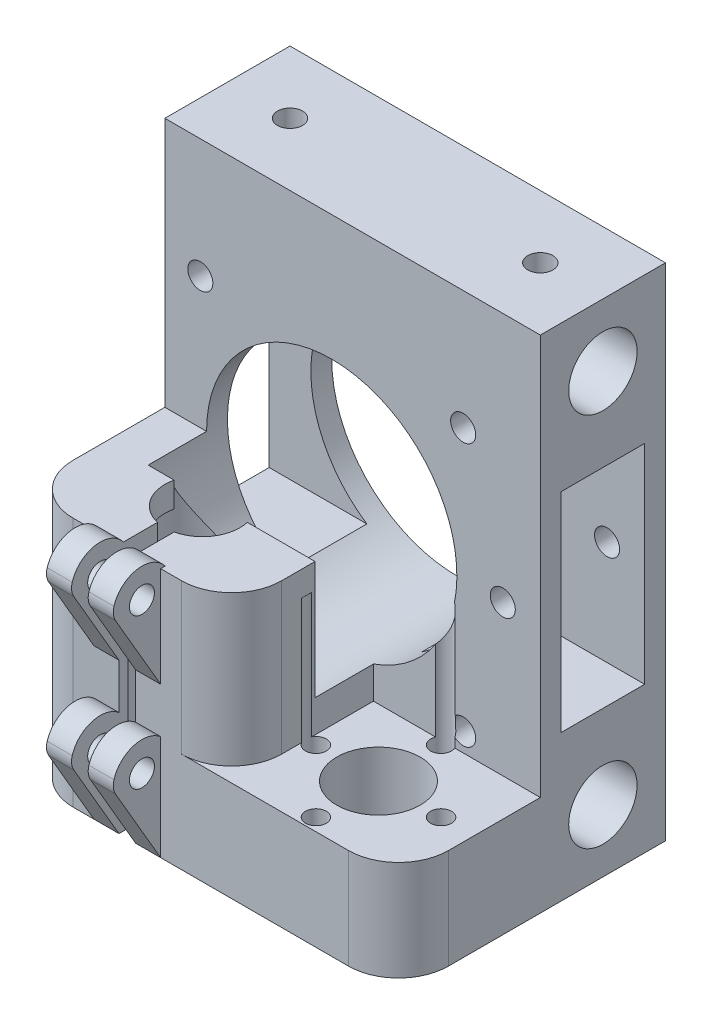
from build123d import *

# Parameters (mm, degrees)
SKETCH1_W           = 45
SKETCH1_H           = 60
BOSS_EXTRUDE1_DEPTH = 15
SKETCH2_R           = 4.1
SKETCH2_W           = 10
SKETCH2_H           = 25
CUT_EXTRUDE1_DEPTH  = 46
SKETCH3_W           = 17
SKETCH3_H           = 12
BOSS_EXTRUDE2_DEPTH = 45
SKETCH4_W           = 25
SKETCH4_H           = 17
BOSS_EXTRUDE3_DEPTH = 18
SKETCH5_W           = 2
SKETCH5_H           = 30
CUT_EXTRUDE2_DEPTH  = 5
SKETCH6_R           = 4.5
CUT_EXTRUDE3_DEPTH  = 61
SKETCH7_R           = 8
SKETCH7_R_2         = 5
SKETCH7_R_3         = 1.25
CUT_EXTRUDE4_DEPTH  = 27
SKETCH8_R           = 15
SKETCH8_R_2         = 1.5
CUT_EXTRUDE5_DEPTH  = 22
FILLET1_R           = 6
SKETCH9_R           = 1.5
CUT_EXTRUDE6_DEPTH  = 15
CUT_EXTRUDE7_REACH  = 62
SKETCH10_R          = 1.5
CUT_EXTRUDE8_START  = -60
SKETCH10_2_R        = 1.5
CUT_EXTRUDE8_DEPTH  = 3.684243
SKETCH11_R          = 1.5
BOSS_EXTRUDE4_DEPTH = 3
BOSS_EXTRUDE6_START = 2
SKETCH11_2_R        = 1.5
BOSS_EXTRUDE6_DEPTH = 3
FILLET3_R           = 2


with BuildPart() as part:
    # Sketch1 → Boss-Extrude1 (new body)
    with BuildSketch(Plane.XY):
        Rectangle(SKETCH1_W, SKETCH1_H)
    extrude(amount=BOSS_EXTRUDE1_DEPTH)

    # Sketch2 → Cut-Extrude1 (cut, through all)
    with BuildSketch(Plane(origin=(22.5, 0, 0), x_dir=(0, 0, -1), z_dir=(1, 0, 0))):
        with Locations((-7.5, 22.5)):
            Circle(SKETCH2_R)
        with Locations((-7.5, -22.5)):
            Circle(SKETCH2_R)
        with Locations((-7.5, 0)):
            Rectangle(SKETCH2_W, SKETCH2_H)
    extrude(amount=-CUT_EXTRUDE1_DEPTH, mode=Mode.SUBTRACT)

    # Sketch3 → Boss-Extrude2 (add)
    with BuildSketch(Plane.ZY.offset(22.5)):
        with Locations((23.5, -24)):
            Rectangle(SKETCH3_W, SKETCH3_H)
    extrude(amount=-BOSS_EXTRUDE2_DEPTH)

    # Sketch4 → Boss-Extrude3 (add)
    with BuildSketch(Plane(origin=(0, -18, 0), x_dir=(1, 0, 0), z_dir=(0, 1, 0))):
        with Locations((-10, -23.5)):
            Rectangle(SKETCH4_W, SKETCH4_H)
    extrude(amount=BOSS_EXTRUDE3_DEPTH)

    # Sketch5 → Cut-Extrude2 (cut)
    with BuildSketch(Plane.XY.offset(32)):
        with Locations((-10, -15)):
            Rectangle(SKETCH5_W, SKETCH5_H)
    extrude(amount=-CUT_EXTRUDE2_DEPTH, mode=Mode.SUBTRACT)

    # Sketch6 → Cut-Extrude3 (cut, through all)
    with BuildSketch(Plane.XZ.offset(30)):
        with Locations((-10, 23)):
            Circle(SKETCH6_R)
    extrude(amount=-CUT_EXTRUDE3_DEPTH, mode=Mode.SUBTRACT)

    # Sketch7 → Cut-Extrude4 (cut)
    with BuildSketch(Plane.XZ.offset(30)):
        with Locations((-10, 23)):
            Circle(SKETCH7_R)
        with Locations((11.1, 23)):
            Circle(SKETCH7_R_2)
        with Locations((18.6, 23)):
            Circle(SKETCH7_R_3)
        with Locations((11.1, 30.5)):
            Circle(SKETCH7_R_3)
        with Locations((11.1, 15.5)):
            Circle(SKETCH7_R_3)
        with Locations((3.6, 23)):
            Circle(SKETCH7_R_3)
    extrude(amount=-CUT_EXTRUDE4_DEPTH, mode=Mode.SUBTRACT)

    # Sketch8 → Cut-Extrude5 (cut)
    with BuildSketch(Plane(origin=(0, 0, 0), x_dir=(-1, 0, 0), z_dir=(0, 0, -1))):
        with Locations((2.5, 0)):
            Circle(SKETCH8_R)
        with Locations((18.25, 15.75)):
            Circle(SKETCH8_R_2)
        with Locations((-13.25, 15.75)):
            Circle(SKETCH8_R_2)
        with Locations((-13.25, -15.75)):
            Circle(SKETCH8_R_2)
        with Locations((18.25, -15.75)):
            Circle(SKETCH8_R_2)
    extrude(amount=-CUT_EXTRUDE5_DEPTH, mode=Mode.SUBTRACT)

    # Fillet1
    fillet1_edges = [part.edges().sort_by_distance(p)[0] for p in [
        (-22.5, -15, 32),
        (22.5, -24, 32),
        (2.5, -9, 32),
    ]]
    fillet(fillet1_edges, radius=FILLET1_R)

    # Sketch9 → Cut-Extrude6 (cut)
    with BuildSketch(Plane(origin=(0, 0, 0), x_dir=(-1, 0, 0), z_dir=(0, 0, -1))):
        with Locations((-18, 0)):
            Circle(SKETCH9_R)
    extrude(amount=-CUT_EXTRUDE6_DEPTH, mode=Mode.SUBTRACT)

    # Sketch10 → Cut-Extrude7 (cut, up to next)
    with BuildSketch(Plane(origin=(0, 30, 0), x_dir=(1, 0, 0), z_dir=(0, 1, 0)), mode=Mode.PRIVATE) as cut_extrude7_sk1:
        with Locations((-15, -7.5)):
            Circle(SKETCH10_R)
    cut_extrude7_tool1 = extrude(cut_extrude7_sk1.sketch, amount=-CUT_EXTRUDE7_REACH, mode=Mode.PRIVATE) & part.part
    add(cut_extrude7_tool1.solids().sort_by_distance((-15, 30, 7.5))[0], mode=Mode.SUBTRACT)
    # Sketch10 → Cut-Extrude7 (cut, up to next)
    with BuildSketch(Plane(origin=(0, 30, 0), x_dir=(1, 0, 0), z_dir=(0, 1, 0)), mode=Mode.PRIVATE) as cut_extrude7_sk2:
        with Locations((15, -7.5)):
            Circle(SKETCH10_R)
    cut_extrude7_tool2 = extrude(cut_extrude7_sk2.sketch, amount=-CUT_EXTRUDE7_REACH, mode=Mode.PRIVATE) & part.part
    add(cut_extrude7_tool2.solids().sort_by_distance((15, 30, 7.5))[0], mode=Mode.SUBTRACT)

    # Sketch10_2 → Cut-Extrude8 (cut)
    with BuildSketch(Plane(origin=(0, 30, 0), x_dir=(1, 0, 0), z_dir=(0, 1, 0)).offset(CUT_EXTRUDE8_START)):
        with Locations((-15, -7.5)):
            Circle(SKETCH10_2_R)
        with Locations((15, -7.5)):
            Circle(SKETCH10_2_R)
    extrude(amount=CUT_EXTRUDE8_DEPTH, mode=Mode.SUBTRACT)

    # Sketch11 → Boss-Extrude4 (add)
    with BuildSketch(Plane(origin=(-11, 0, 0), x_dir=(0, 0, -1), z_dir=(1, 0, 0))):
        with BuildLine():
            Line((-32, -30), (-37.75, -20.113140033))
            ThreePointArc((-37.75, -20.113140033), (-34.822445965, -16.660270847), (-30.937253933, -18.983665157))
            Line((-30.937253933, -18.983665157), (-30.937253933, -30))
            Line((-30.937253933, -30), (-32, -30))
        make_face()
        with Locations((-34.25, -20.113140033)):
            Circle(SKETCH11_R, mode=Mode.SUBTRACT)
        with BuildLine():
            Line((-32, -12), (-37.75, -2.113140033))
            ThreePointArc((-37.75, -2.113140033), (-34.822445965, 1.339729153), (-30.937253933, -0.983665157))
            Line((-30.937253933, -0.983665157), (-30.937253933, -12))
            Line((-30.937253933, -12), (-32, -12))
        make_face()
        with Locations((-34.25, -2.113140033)):
            Circle(SKETCH11_R, mode=Mode.SUBTRACT)
    extrude(amount=-BOSS_EXTRUDE4_DEPTH)

    # Sketch11_2 → Boss-Extrude6 (add)
    with BuildSketch(Plane(origin=(-11, 0, 0), x_dir=(0, 0, -1), z_dir=(1, 0, 0)).offset(BOSS_EXTRUDE6_START)):
        with BuildLine():
            Line((-32, -30), (-37.75, -20.113140033))
            ThreePointArc((-37.75, -20.113140033), (-34.822445965, -16.660270847), (-30.937253933, -18.983665157))
            Line((-30.937253933, -18.983665157), (-30.937253933, -30))
            Line((-30.937253933, -30), (-32, -30))
        make_face()
        with Locations((-34.25, -20.113140033)):
            Circle(SKETCH11_2_R, mode=Mode.SUBTRACT)
        with BuildLine():
            Line((-32, -12), (-37.75, -2.113140033))
            ThreePointArc((-37.75, -2.113140033), (-34.822445965, 1.339729153), (-30.937253933, -0.983665157))
            Line((-30.937253933, -0.983665157), (-30.937253933, -12))
            Line((-30.937253933, -12), (-32, -12))
        make_face()
        with Locations((-34.25, -2.113140033)):
            Circle(SKETCH11_2_R, mode=Mode.SUBTRACT)
    extrude(amount=BOSS_EXTRUDE6_DEPTH)

    # Fillet3
    fillet3_edges = [part.edges().sort_by_distance(p)[0] for p in [
        (-12.5, -20.113140033, 37.75),
        (-12.5, -2.113140033, 37.75),
        (-7.5, -20.113140033, 37.75),
        (-7.5, -2.113140033, 37.75),
    ]]
    fillet(fillet3_edges, radius=FILLET3_R)


solid = part.part
